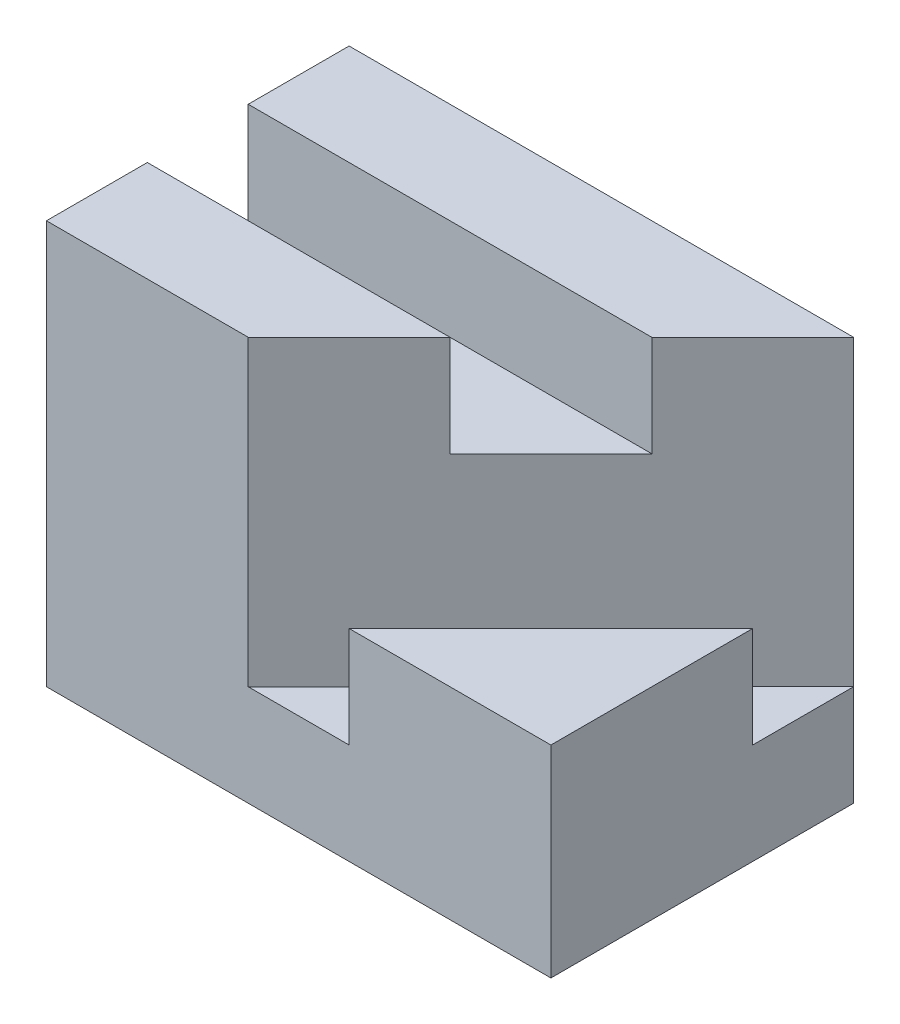
from build123d import *

# Parameters (mm, degrees)
SKETCH_1_W          = 25
SKETCH_1_H          = 15
EXTRUDE_1_DEPTH     = 20
CUT_EXTRUDE_1_DEPTH = 5
CUT_EXTRUDE_2_DEPTH = 15
CUT_EXTRUDE_3_DEPTH = 10


with BuildPart() as part:
    # 草圖1 → 填料-伸長1 (new body)
    with BuildSketch(Plane(origin=(0, 0, 0), x_dir=(1, 0, 0), z_dir=(0, 1, 0))):
        Rectangle(SKETCH_1_W, SKETCH_1_H)
    extrude(amount=EXTRUDE_1_DEPTH)

    # 草圖3 → 除料-伸長1 (cut)
    with BuildSketch(Plane(origin=(0, 20, 0), x_dir=(1, 0, 0), z_dir=(0, 1, 0))):
        Polygon((-12.5, 2.5), (-12.5, -2.5), (2.5, -2.5), (-2.5, -7.5), (12.5, -7.5), (12.5, 7.5), (7.5, 2.5), align=None)
    extrude(amount=-CUT_EXTRUDE_1_DEPTH, mode=Mode.SUBTRACT)

    # 草圖3<3> → 除料-伸長2 (cut)
    with BuildSketch(Plane(origin=(0, 20, 0), x_dir=(1, 0, 0), z_dir=(0, 1, 0))):
        Polygon((7.5, 2.5), (2.5, -2.5), (-2.5, -7.5), (2.5, -7.5), (12.5, 2.5), (12.5, 7.5), align=None)
    extrude(amount=-CUT_EXTRUDE_2_DEPTH, mode=Mode.SUBTRACT)

    # 草圖3<4> → 除料-伸長3 (cut)
    with BuildSketch(Plane(origin=(0, 20, 0), x_dir=(1, 0, 0), z_dir=(0, 1, 0))):
        Polygon((12.5, 2.5), (2.5, -7.5), (12.5, -7.5), align=None)
    extrude(amount=-CUT_EXTRUDE_3_DEPTH, mode=Mode.SUBTRACT)


solid = part.part
